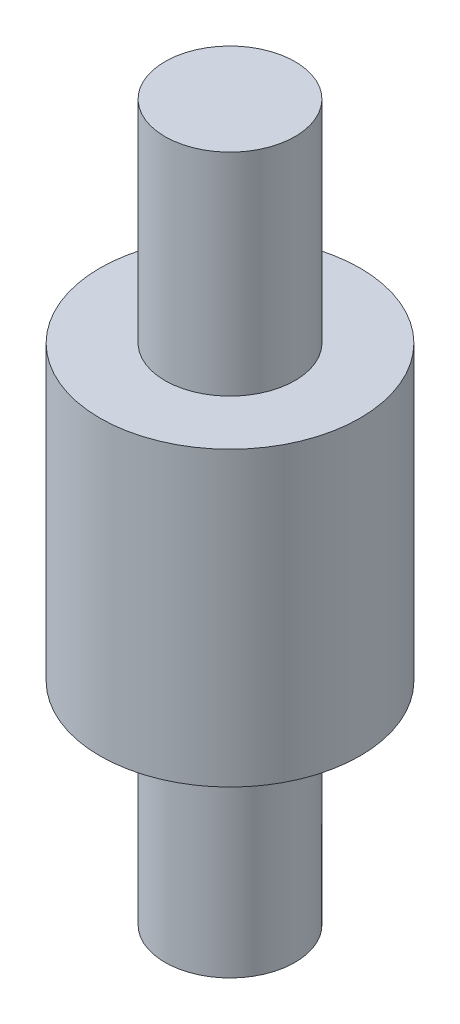
from build123d import *

# Parameters (mm, degrees)
SKETCH_1_R      = 8
EXTRUDE_1_DEPTH = 18
SKETCH_2_R      = 4
EXTRUDE_2_DEPTH = 13
SKETCH_3_R      = 4
EXTRUDE_3_DEPTH = 13


with BuildPart() as part:
    # 草图1 → 凸台-拉伸1 (new body)
    with BuildSketch(Plane(origin=(0, 0, 0), x_dir=(1, 0, 0), z_dir=(0, 1, 0))):
        Circle(SKETCH_1_R)
    extrude(amount=EXTRUDE_1_DEPTH)

    # 草图2 → 凸台-拉伸2 (add)
    with BuildSketch(Plane(origin=(0, 18, 0), x_dir=(1, 0, 0), z_dir=(0, 1, 0))):
        Circle(SKETCH_2_R)
    extrude(amount=EXTRUDE_2_DEPTH)

    # 草图3 → 凸台-拉伸3 (add)
    with BuildSketch(Plane.XZ):
        Circle(SKETCH_3_R)
    extrude(amount=EXTRUDE_3_DEPTH)


solid = part.part
